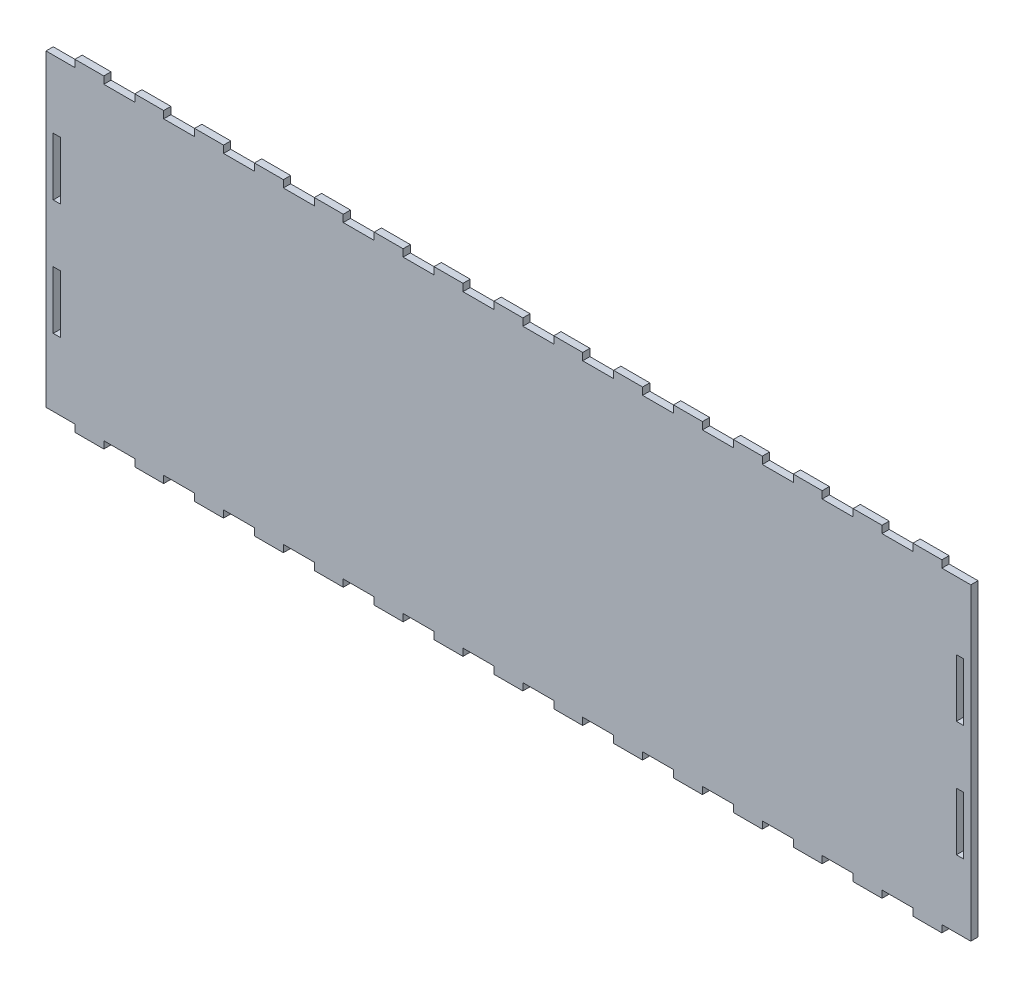
from build123d import *

# Parameters (mm, degrees)
SKETCH1_W           = 3.175
SKETCH1_H           = 25.4
BOSS_EXTRUDE1_DEPTH = 3.175


with BuildPart() as part:
    # Sketch1 → Boss-Extrude1 (new body)
    with BuildSketch(Plane.XY):
        Polygon((65.314285714, 135.64235), (65.214285714, 135.64235), (51.807142857, 135.64235), (51.707142857, 135.64235), (51.707142857, 138.81735), (39.007142857, 138.81735), (39.007142857, 135.64235), (38.907142857, 135.64235), (25.5, 135.64235), (25.4, 135.64235), (25.4, 138.81735), (12.7, 138.81735), (12.7, 135.64235), (12.6, 135.64235), (0, 135.64235), (0, 0), (12.6, 0), (12.7, 0), (12.7, -3.175), (25.4, -3.175), (25.4, 0), (25.5, 0), (38.907142857, 0), (39.007142857, 0), (39.007142857, -3.175), (51.707142857, -3.175), (51.707142857, 0), (51.807142857, 0), (65.214285714, 0), (65.314285714, 0), (65.314285714, -3.175), (78.014285714, -3.175), (78.014285714, 0), (78.114285714, 0), (91.521428571, 0), (91.621428571, 0), (91.621428571, -3.175), (104.321428571, -3.175), (104.321428571, 0), (104.421428571, 0), (117.828571429, 0), (117.928571429, 0), (117.928571429, -3.175), (130.628571429, -3.175), (130.628571429, 0), (130.728571429, 0), (144.135714286, 0), (144.235714286, 0), (144.235714286, -3.175), (156.935714286, -3.175), (156.935714286, 0), (157.035714286, 0), (170.442857143, 0), (170.542857143, 0), (170.542857143, -3.175), (183.242857143, -3.175), (183.242857143, 0), (183.342857143, 0), (196.75, 0), (196.85, 0), (196.85, -3.175), (209.55, -3.175), (209.55, 0), (209.65, 0), (223.057142857, 0), (223.157142857, 0), (223.157142857, -3.175), (235.857142857, -3.175), (235.857142857, 0), (235.957142857, 0), (249.364285714, 0), (249.464285714, 0), (249.464285714, -3.175), (262.164285714, -3.175), (262.164285714, 0), (262.264285714, 0), (275.671428571, 0), (275.771428571, 0), (275.771428571, -3.175), (288.471428571, -3.175), (288.471428571, 0), (288.571428571, 0), (301.978571429, 0), (302.078571429, 0), (302.078571429, -3.175), (314.778571429, -3.175), (314.778571429, 0), (314.878571429, 0), (328.285714286, 0), (328.385714286, 0), (328.385714286, -3.175), (341.085714286, -3.175), (341.085714286, 0), (341.185714286, 0), (354.592857143, 0), (354.692857143, 0), (354.692857143, -3.175), (367.392857143, -3.175), (367.392857143, 0), (367.492857143, 0), (380.9, 0), (381, 0), (381, -3.175), (393.7, -3.175), (393.7, 0), (393.8, 0), (406.4, 0), (406.4, 135.64235), (393.8, 135.64235), (393.7, 135.64235), (393.7, 138.81735), (381, 138.81735), (381, 135.64235), (380.9, 135.64235), (367.492857143, 135.64235), (367.392857143, 135.64235), (367.392857143, 138.81735), (354.692857143, 138.81735), (354.692857143, 135.64235), (354.592857143, 135.64235), (341.185714286, 135.64235), (341.085714286, 135.64235), (341.085714286, 138.81735), (328.385714286, 138.81735), (328.385714286, 135.64235), (328.285714286, 135.64235), (314.878571429, 135.64235), (314.778571429, 135.64235), (314.778571429, 138.81735), (302.078571429, 138.81735), (302.078571429, 135.64235), (301.978571429, 135.64235), (288.571428571, 135.64235), (288.471428571, 135.64235), (288.471428571, 138.81735), (275.771428571, 138.81735), (275.771428571, 135.64235), (275.671428571, 135.64235), (262.264285714, 135.64235), (262.164285714, 135.64235), (262.164285714, 138.81735), (249.464285714, 138.81735), (249.464285714, 135.64235), (249.364285714, 135.64235), (235.957142857, 135.64235), (235.857142857, 135.64235), (235.857142857, 138.81735), (223.157142857, 138.81735), (223.157142857, 135.64235), (223.057142857, 135.64235), (209.65, 135.64235), (209.55, 135.64235), (209.55, 138.81735), (196.85, 138.81735), (196.85, 135.64235), (196.75, 135.64235), (183.342857143, 135.64235), (183.242857143, 135.64235), (183.242857143, 138.81735), (170.542857143, 138.81735), (170.542857143, 135.64235), (170.442857143, 135.64235), (157.035714286, 135.64235), (156.935714286, 135.64235), (156.935714286, 138.81735), (144.235714286, 138.81735), (144.235714286, 135.64235), (144.135714286, 135.64235), (130.728571429, 135.64235), (130.628571429, 135.64235), (130.628571429, 138.81735), (117.928571429, 138.81735), (117.928571429, 135.64235), (117.828571429, 135.64235), (104.421428571, 135.64235), (104.321428571, 135.64235), (104.321428571, 138.81735), (91.621428571, 138.81735), (91.621428571, 135.64235), (91.521428571, 135.64235), (78.114285714, 135.64235), (78.014285714, 135.64235), (78.014285714, 138.81735), (65.314285714, 138.81735), align=None)
        with Locations((401.6375, 93.221175)):
            Rectangle(SKETCH1_W, SKETCH1_H, mode=Mode.SUBTRACT)
        with Locations((401.6375, 42.421175)):
            Rectangle(SKETCH1_W, SKETCH1_H, mode=Mode.SUBTRACT)
        with Locations((4.7625, 93.221175)):
            Rectangle(SKETCH1_W, SKETCH1_H, mode=Mode.SUBTRACT)
        with Locations((4.7625, 42.421175)):
            Rectangle(SKETCH1_W, SKETCH1_H, mode=Mode.SUBTRACT)
    extrude(amount=BOSS_EXTRUDE1_DEPTH)


solid = part.part
